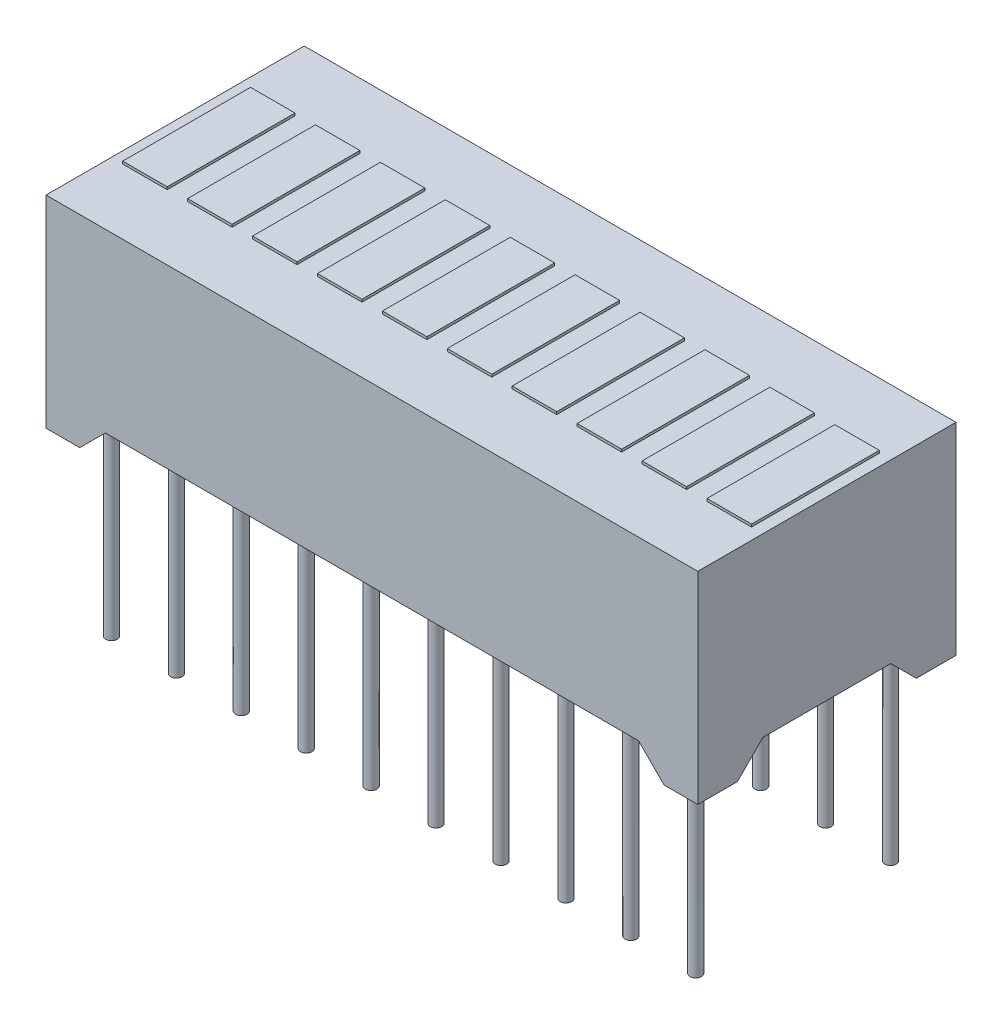
from build123d import *

# Parameters (mm, degrees)
CROQUIS2_W                          = 25.5
CROQUIS2_H                          = 10.1
SALIENTE_EXTRUIR2_DEPTH             = 7.9
CORTAR_EXTRUIR1_DEPTH               = 26.5
CROQUIS4_W                          = 1.74
CROQUIS4_H                          = 5
SALIENTE_EXTRUIR3_DEPTH             = 0.1
CORTAR_EXTRUIR2_DEPTH               = 11.1
CROQUIS7_R                          = 0.225
SALIENTE_EXTRUIR4_DEPTH             = 7
SALIENTE_EXTRUIR4_DIRECTION_2_REACH = 10


with BuildPart() as part:
    # Croquis2 → Saliente-Extruir2 (new body)
    with BuildSketch(Plane(origin=(0, 0, 0), x_dir=(1, 0, 0), z_dir=(0, 1, 0))):
        with Locations((12.75, 5.05)):
            Rectangle(CROQUIS2_W, CROQUIS2_H)
    extrude(amount=SALIENTE_EXTRUIR2_DEPTH)

    # Croquis3 → Cortar-Extruir1 (cut, through all)
    with BuildSketch(Plane(origin=(25.5, 0, 0), x_dir=(0, 0, -1), z_dir=(1, 0, 0))):
        Polygon((1.55, 0), (2.55, 1), (7.55, 1), (8.55, 0), align=None)
    extrude(amount=-CORTAR_EXTRUIR1_DEPTH, mode=Mode.SUBTRACT)

    # Croquis4 → Saliente-Extruir3 (add)
    with BuildSketch(Plane(origin=(0, 7.9, 0), x_dir=(1, 0, 0), z_dir=(0, 1, 0))):
        with Locations((1.32, 5.05)):
            Rectangle(CROQUIS4_W, CROQUIS4_H)
        with Locations((3.86, 5.05)):
            Rectangle(CROQUIS4_W, CROQUIS4_H)
        with Locations((6.4, 5.05)):
            Rectangle(CROQUIS4_W, CROQUIS4_H)
        with Locations((8.94, 5.05)):
            Rectangle(CROQUIS4_W, CROQUIS4_H)
        with Locations((11.48, 5.05)):
            Rectangle(CROQUIS4_W, CROQUIS4_H)
        with Locations((14.02, 5.05)):
            Rectangle(CROQUIS4_W, CROQUIS4_H)
        with Locations((16.56, 5.05)):
            Rectangle(CROQUIS4_W, CROQUIS4_H)
        with Locations((19.1, 5.05)):
            Rectangle(CROQUIS4_W, CROQUIS4_H)
        with Locations((21.64, 5.05)):
            Rectangle(CROQUIS4_W, CROQUIS4_H)
        with Locations((24.18, 5.05)):
            Rectangle(CROQUIS4_W, CROQUIS4_H)
    extrude(amount=SALIENTE_EXTRUIR3_DEPTH)

    # Croquis6 → Cortar-Extruir2 (cut, through all)
    with BuildSketch(Plane(origin=(0, 0, -10.1), x_dir=(-1, 0, 0), z_dir=(0, 0, -1))):
        Polygon((-23.18, 1), (-24.18, 0), (-1.32, 0), (-2.32, 1), align=None)
    extrude(amount=-CORTAR_EXTRUIR2_DEPTH, mode=Mode.SUBTRACT)

    # Croquis7 → Saliente-Extruir4 (add)
    with BuildSketch(Plane.XZ):
        with Locations((1.32, -8.86)):
            Circle(CROQUIS7_R)
        with Locations((3.86, -8.86)):
            Circle(CROQUIS7_R)
        with Locations((6.4, -8.86)):
            Circle(CROQUIS7_R)
        with Locations((8.94, -8.86)):
            Circle(CROQUIS7_R)
        with Locations((11.48, -8.86)):
            Circle(CROQUIS7_R)
        with Locations((14.02, -8.86)):
            Circle(CROQUIS7_R)
        with Locations((16.56, -8.86)):
            Circle(CROQUIS7_R)
        with Locations((19.1, -8.86)):
            Circle(CROQUIS7_R)
        with Locations((21.64, -8.86)):
            Circle(CROQUIS7_R)
        with Locations((24.18, -8.86)):
            Circle(CROQUIS7_R)
        with Locations((3.86, -1.24)):
            Circle(CROQUIS7_R)
        with Locations((6.4, -1.24)):
            Circle(CROQUIS7_R)
        with Locations((8.94, -1.24)):
            Circle(CROQUIS7_R)
        with Locations((11.48, -1.24)):
            Circle(CROQUIS7_R)
        with Locations((14.02, -1.24)):
            Circle(CROQUIS7_R)
        with Locations((16.56, -1.24)):
            Circle(CROQUIS7_R)
        with Locations((19.1, -1.24)):
            Circle(CROQUIS7_R)
        with Locations((21.64, -1.24)):
            Circle(CROQUIS7_R)
        with Locations((24.18, -1.24)):
            Circle(CROQUIS7_R)
        with Locations((1.32, -1.24)):
            Circle(CROQUIS7_R)
    extrude(amount=SALIENTE_EXTRUIR4_DEPTH)

    # Croquis7 → Saliente-Extruir4 direction 2 (add, up to next)
    with BuildSketch(Plane.XZ, mode=Mode.PRIVATE) as saliente_extruir4_direction_2_sk1:
        with Locations((1.32, -8.86)):
            Circle(CROQUIS7_R)
    saliente_extruir4_direction_2_tool1 = extrude(saliente_extruir4_direction_2_sk1.sketch, amount=-SALIENTE_EXTRUIR4_DIRECTION_2_REACH, mode=Mode.PRIVATE) - part.part
    add(saliente_extruir4_direction_2_tool1.solids().sort_by_distance((1.32, 0, -8.86))[0])
    # Croquis7 → Saliente-Extruir4 direction 2 (add, up to next)
    with BuildSketch(Plane.XZ, mode=Mode.PRIVATE) as saliente_extruir4_direction_2_sk2:
        with Locations((3.86, -8.86)):
            Circle(CROQUIS7_R)
    saliente_extruir4_direction_2_tool2 = extrude(saliente_extruir4_direction_2_sk2.sketch, amount=-SALIENTE_EXTRUIR4_DIRECTION_2_REACH, mode=Mode.PRIVATE) - part.part
    add(saliente_extruir4_direction_2_tool2.solids().sort_by_distance((3.86, 0, -8.86))[0])
    # Croquis7 → Saliente-Extruir4 direction 2 (add, up to next)
    with BuildSketch(Plane.XZ, mode=Mode.PRIVATE) as saliente_extruir4_direction_2_sk3:
        with Locations((6.4, -8.86)):
            Circle(CROQUIS7_R)
    saliente_extruir4_direction_2_tool3 = extrude(saliente_extruir4_direction_2_sk3.sketch, amount=-SALIENTE_EXTRUIR4_DIRECTION_2_REACH, mode=Mode.PRIVATE) - part.part
    add(saliente_extruir4_direction_2_tool3.solids().sort_by_distance((6.4, 0, -8.86))[0])
    # Croquis7 → Saliente-Extruir4 direction 2 (add, up to next)
    with BuildSketch(Plane.XZ, mode=Mode.PRIVATE) as saliente_extruir4_direction_2_sk4:
        with Locations((8.94, -8.86)):
            Circle(CROQUIS7_R)
    saliente_extruir4_direction_2_tool4 = extrude(saliente_extruir4_direction_2_sk4.sketch, amount=-SALIENTE_EXTRUIR4_DIRECTION_2_REACH, mode=Mode.PRIVATE) - part.part
    add(saliente_extruir4_direction_2_tool4.solids().sort_by_distance((8.94, 0, -8.86))[0])
    # Croquis7 → Saliente-Extruir4 direction 2 (add, up to next)
    with BuildSketch(Plane.XZ, mode=Mode.PRIVATE) as saliente_extruir4_direction_2_sk5:
        with Locations((11.48, -8.86)):
            Circle(CROQUIS7_R)
    saliente_extruir4_direction_2_tool5 = extrude(saliente_extruir4_direction_2_sk5.sketch, amount=-SALIENTE_EXTRUIR4_DIRECTION_2_REACH, mode=Mode.PRIVATE) - part.part
    add(saliente_extruir4_direction_2_tool5.solids().sort_by_distance((11.48, 0, -8.86))[0])
    # Croquis7 → Saliente-Extruir4 direction 2 (add, up to next)
    with BuildSketch(Plane.XZ, mode=Mode.PRIVATE) as saliente_extruir4_direction_2_sk6:
        with Locations((14.02, -8.86)):
            Circle(CROQUIS7_R)
    saliente_extruir4_direction_2_tool6 = extrude(saliente_extruir4_direction_2_sk6.sketch, amount=-SALIENTE_EXTRUIR4_DIRECTION_2_REACH, mode=Mode.PRIVATE) - part.part
    add(saliente_extruir4_direction_2_tool6.solids().sort_by_distance((14.02, 0, -8.86))[0])
    # Croquis7 → Saliente-Extruir4 direction 2 (add, up to next)
    with BuildSketch(Plane.XZ, mode=Mode.PRIVATE) as saliente_extruir4_direction_2_sk7:
        with Locations((16.56, -8.86)):
            Circle(CROQUIS7_R)
    saliente_extruir4_direction_2_tool7 = extrude(saliente_extruir4_direction_2_sk7.sketch, amount=-SALIENTE_EXTRUIR4_DIRECTION_2_REACH, mode=Mode.PRIVATE) - part.part
    add(saliente_extruir4_direction_2_tool7.solids().sort_by_distance((16.56, 0, -8.86))[0])
    # Croquis7 → Saliente-Extruir4 direction 2 (add, up to next)
    with BuildSketch(Plane.XZ, mode=Mode.PRIVATE) as saliente_extruir4_direction_2_sk8:
        with Locations((19.1, -8.86)):
            Circle(CROQUIS7_R)
    saliente_extruir4_direction_2_tool8 = extrude(saliente_extruir4_direction_2_sk8.sketch, amount=-SALIENTE_EXTRUIR4_DIRECTION_2_REACH, mode=Mode.PRIVATE) - part.part
    add(saliente_extruir4_direction_2_tool8.solids().sort_by_distance((19.1, 0, -8.86))[0])
    # Croquis7 → Saliente-Extruir4 direction 2 (add, up to next)
    with BuildSketch(Plane.XZ, mode=Mode.PRIVATE) as saliente_extruir4_direction_2_sk9:
        with Locations((21.64, -8.86)):
            Circle(CROQUIS7_R)
    saliente_extruir4_direction_2_tool9 = extrude(saliente_extruir4_direction_2_sk9.sketch, amount=-SALIENTE_EXTRUIR4_DIRECTION_2_REACH, mode=Mode.PRIVATE) - part.part
    add(saliente_extruir4_direction_2_tool9.solids().sort_by_distance((21.64, 0, -8.86))[0])
    # Croquis7 → Saliente-Extruir4 direction 2 (add, up to next)
    with BuildSketch(Plane.XZ, mode=Mode.PRIVATE) as saliente_extruir4_direction_2_sk10:
        with Locations((24.18, -8.86)):
            Circle(CROQUIS7_R)
    saliente_extruir4_direction_2_tool10 = extrude(saliente_extruir4_direction_2_sk10.sketch, amount=-SALIENTE_EXTRUIR4_DIRECTION_2_REACH, mode=Mode.PRIVATE) - part.part
    add(saliente_extruir4_direction_2_tool10.solids().sort_by_distance((24.18, 0, -8.86))[0])
    # Croquis7 → Saliente-Extruir4 direction 2 (add, up to next)
    with BuildSketch(Plane.XZ, mode=Mode.PRIVATE) as saliente_extruir4_direction_2_sk11:
        with Locations((3.86, -1.24)):
            Circle(CROQUIS7_R)
    saliente_extruir4_direction_2_tool11 = extrude(saliente_extruir4_direction_2_sk11.sketch, amount=-SALIENTE_EXTRUIR4_DIRECTION_2_REACH, mode=Mode.PRIVATE) - part.part
    add(saliente_extruir4_direction_2_tool11.solids().sort_by_distance((3.86, 0, -1.24))[0])
    # Croquis7 → Saliente-Extruir4 direction 2 (add, up to next)
    with BuildSketch(Plane.XZ, mode=Mode.PRIVATE) as saliente_extruir4_direction_2_sk12:
        with Locations((6.4, -1.24)):
            Circle(CROQUIS7_R)
    saliente_extruir4_direction_2_tool12 = extrude(saliente_extruir4_direction_2_sk12.sketch, amount=-SALIENTE_EXTRUIR4_DIRECTION_2_REACH, mode=Mode.PRIVATE) - part.part
    add(saliente_extruir4_direction_2_tool12.solids().sort_by_distance((6.4, 0, -1.24))[0])
    # Croquis7 → Saliente-Extruir4 direction 2 (add, up to next)
    with BuildSketch(Plane.XZ, mode=Mode.PRIVATE) as saliente_extruir4_direction_2_sk13:
        with Locations((8.94, -1.24)):
            Circle(CROQUIS7_R)
    saliente_extruir4_direction_2_tool13 = extrude(saliente_extruir4_direction_2_sk13.sketch, amount=-SALIENTE_EXTRUIR4_DIRECTION_2_REACH, mode=Mode.PRIVATE) - part.part
    add(saliente_extruir4_direction_2_tool13.solids().sort_by_distance((8.94, 0, -1.24))[0])
    # Croquis7 → Saliente-Extruir4 direction 2 (add, up to next)
    with BuildSketch(Plane.XZ, mode=Mode.PRIVATE) as saliente_extruir4_direction_2_sk14:
        with Locations((11.48, -1.24)):
            Circle(CROQUIS7_R)
    saliente_extruir4_direction_2_tool14 = extrude(saliente_extruir4_direction_2_sk14.sketch, amount=-SALIENTE_EXTRUIR4_DIRECTION_2_REACH, mode=Mode.PRIVATE) - part.part
    add(saliente_extruir4_direction_2_tool14.solids().sort_by_distance((11.48, 0, -1.24))[0])
    # Croquis7 → Saliente-Extruir4 direction 2 (add, up to next)
    with BuildSketch(Plane.XZ, mode=Mode.PRIVATE) as saliente_extruir4_direction_2_sk15:
        with Locations((14.02, -1.24)):
            Circle(CROQUIS7_R)
    saliente_extruir4_direction_2_tool15 = extrude(saliente_extruir4_direction_2_sk15.sketch, amount=-SALIENTE_EXTRUIR4_DIRECTION_2_REACH, mode=Mode.PRIVATE) - part.part
    add(saliente_extruir4_direction_2_tool15.solids().sort_by_distance((14.02, 0, -1.24))[0])
    # Croquis7 → Saliente-Extruir4 direction 2 (add, up to next)
    with BuildSketch(Plane.XZ, mode=Mode.PRIVATE) as saliente_extruir4_direction_2_sk16:
        with Locations((16.56, -1.24)):
            Circle(CROQUIS7_R)
    saliente_extruir4_direction_2_tool16 = extrude(saliente_extruir4_direction_2_sk16.sketch, amount=-SALIENTE_EXTRUIR4_DIRECTION_2_REACH, mode=Mode.PRIVATE) - part.part
    add(saliente_extruir4_direction_2_tool16.solids().sort_by_distance((16.56, 0, -1.24))[0])
    # Croquis7 → Saliente-Extruir4 direction 2 (add, up to next)
    with BuildSketch(Plane.XZ, mode=Mode.PRIVATE) as saliente_extruir4_direction_2_sk17:
        with Locations((19.1, -1.24)):
            Circle(CROQUIS7_R)
    saliente_extruir4_direction_2_tool17 = extrude(saliente_extruir4_direction_2_sk17.sketch, amount=-SALIENTE_EXTRUIR4_DIRECTION_2_REACH, mode=Mode.PRIVATE) - part.part
    add(saliente_extruir4_direction_2_tool17.solids().sort_by_distance((19.1, 0, -1.24))[0])
    # Croquis7 → Saliente-Extruir4 direction 2 (add, up to next)
    with BuildSketch(Plane.XZ, mode=Mode.PRIVATE) as saliente_extruir4_direction_2_sk18:
        with Locations((21.64, -1.24)):
            Circle(CROQUIS7_R)
    saliente_extruir4_direction_2_tool18 = extrude(saliente_extruir4_direction_2_sk18.sketch, amount=-SALIENTE_EXTRUIR4_DIRECTION_2_REACH, mode=Mode.PRIVATE) - part.part
    add(saliente_extruir4_direction_2_tool18.solids().sort_by_distance((21.64, 0, -1.24))[0])
    # Croquis7 → Saliente-Extruir4 direction 2 (add, up to next)
    with BuildSketch(Plane.XZ, mode=Mode.PRIVATE) as saliente_extruir4_direction_2_sk19:
        with Locations((24.18, -1.24)):
            Circle(CROQUIS7_R)
    saliente_extruir4_direction_2_tool19 = extrude(saliente_extruir4_direction_2_sk19.sketch, amount=-SALIENTE_EXTRUIR4_DIRECTION_2_REACH, mode=Mode.PRIVATE) - part.part
    add(saliente_extruir4_direction_2_tool19.solids().sort_by_distance((24.18, 0, -1.24))[0])
    # Croquis7 → Saliente-Extruir4 direction 2 (add, up to next)
    with BuildSketch(Plane.XZ, mode=Mode.PRIVATE) as saliente_extruir4_direction_2_sk20:
        with Locations((1.32, -1.24)):
            Circle(CROQUIS7_R)
    saliente_extruir4_direction_2_tool20 = extrude(saliente_extruir4_direction_2_sk20.sketch, amount=-SALIENTE_EXTRUIR4_DIRECTION_2_REACH, mode=Mode.PRIVATE) - part.part
    add(saliente_extruir4_direction_2_tool20.solids().sort_by_distance((1.32, 0, -1.24))[0])


solid = part.part
